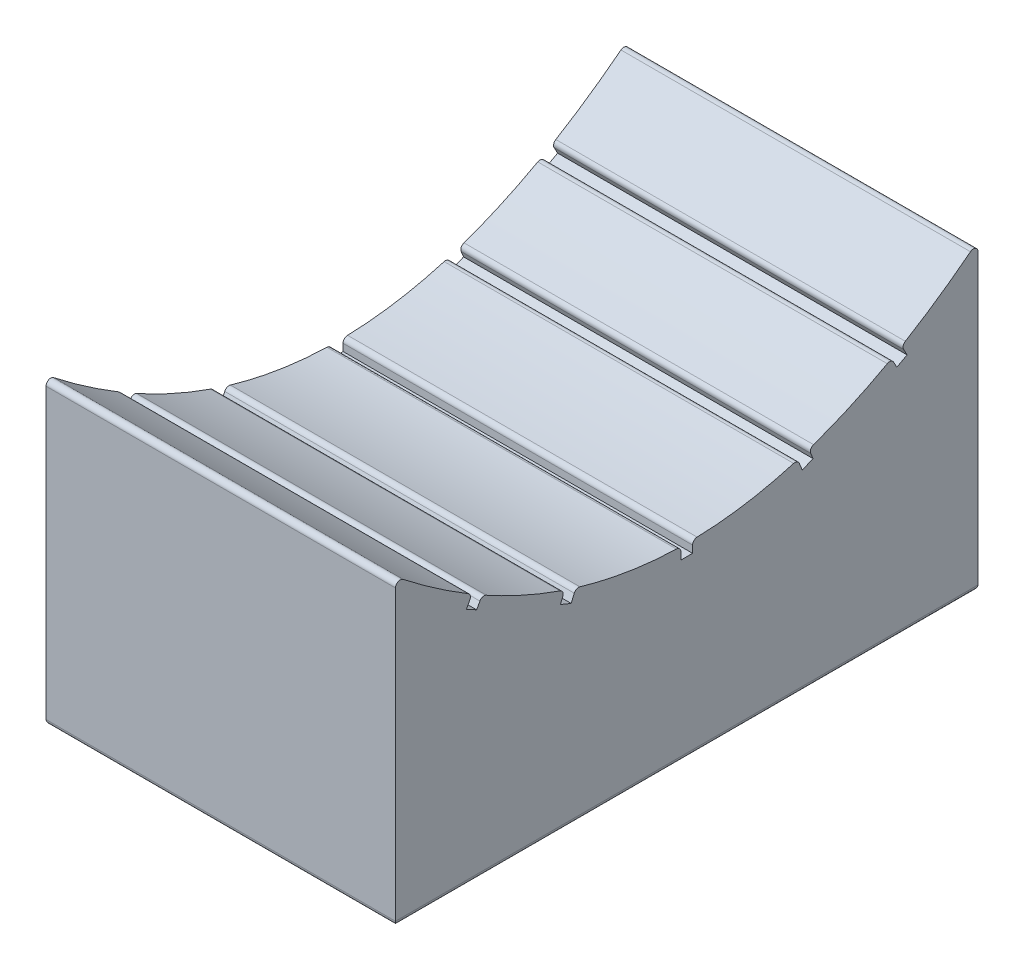
from build123d import *

# Parameters (mm, degrees)
BOSS_EXTRUDE1_DEPTH = 15
SKETCH2_W           = 1.2
SKETCH2_H           = 4
CUT_EXTRUDE1_DEPTH  = 7
SKETCH3_W           = 0.5
SKETCH3_H           = 1
CUT_EXTRUDE2_DEPTH  = 37
FILLET1_R           = 0.2


with BuildPart() as part:
    # Sketch1 → Boss-Extrude1 (new body)
    with BuildSketch(Plane(origin=(0, 0, 0), x_dir=(0, 0, -1), z_dir=(1, 0, 0))):
        with BuildLine():
            Line((0, 0), (25, 0))
            Line((25, 0), (25, 13))
            add(Edge.make_bspline(
                [(0, 13), (12.5, 3), (25, 13)],
                knots=[0, 0, 0, 1, 1, 1], degree=2))
            Line((0, 13), (0, 0))
        make_face()
    extrude(amount=BOSS_EXTRUDE1_DEPTH)

    # Sketch2 → Cut-Extrude1 (cut)
    with BuildSketch(Plane.XZ):
        with Locations((7.5, -12.5)):
            Rectangle(SKETCH2_W, SKETCH2_H)
    extrude(amount=-CUT_EXTRUDE1_DEPTH, mode=Mode.SUBTRACT)

    # Sketch3 → Cut-Extrude2 (cut)
    with BuildSketch(Plane(origin=(15, 0, 0), x_dir=(0, 0, -1), z_dir=(1, 0, 0))):
        Polygon((3.042767166, 10.270382004), (3.517045304, 11.150757065), (3.957232834, 10.913617996), (3.482954696, 10.033242935), align=None)
        Polygon((7.078458916, 8.432844564), (7.459200301, 9.357526129), (7.921541084, 9.167155436), (7.540799699, 8.242473871), align=None)
        with Locations((12.5, 8)):
            Rectangle(SKETCH3_W, SKETCH3_H)
        Polygon((17.459200301, 8.242473871), (17.078458916, 9.167155436), (17.540799699, 9.357526129), (17.921541084, 8.432844564), align=None)
        Polygon((21.517045304, 10.033242935), (21.042767166, 10.913617996), (21.482954696, 11.150757065), (21.957232834, 10.270382004), align=None)
    extrude(amount=-CUT_EXTRUDE2_DEPTH, mode=Mode.SUBTRACT)

    # Fillet1
    fillet1_edges = [part.edges().sort_by_distance(p)[0] for p in [
        (7.5, 0, 0),
        (15, 0, -12.5),
        (7.5, 0, -25),
        (0, 0, -12.5),
        (6.9, 0, -12.5),
        (7.5, 0, -14.5),
        (8.1, 0, -12.5),
        (7.5, 0, -10.5),
        (7.5, 13, 0),
        (7.5, 13, -25),
        (7.5, 10.717971581, -3.283893886),
        (7.5, 10.468322589, -3.717342036),
        (7.5, 8.878048552, -7.261773464),
        (7.5, 8.725178663, -7.739555355),
        (7.5, 8.002, -12.25),
        (7.5, 8.002, -12.75),
        (7.5, 8.725178663, -17.260444645),
        (7.5, 8.878048552, -17.738226536),
        (7.5, 10.468322589, -21.282657964),
        (7.5, 10.717971581, -21.716106114),
    ]]
    fillet(fillet1_edges, radius=FILLET1_R)


solid = part.part
